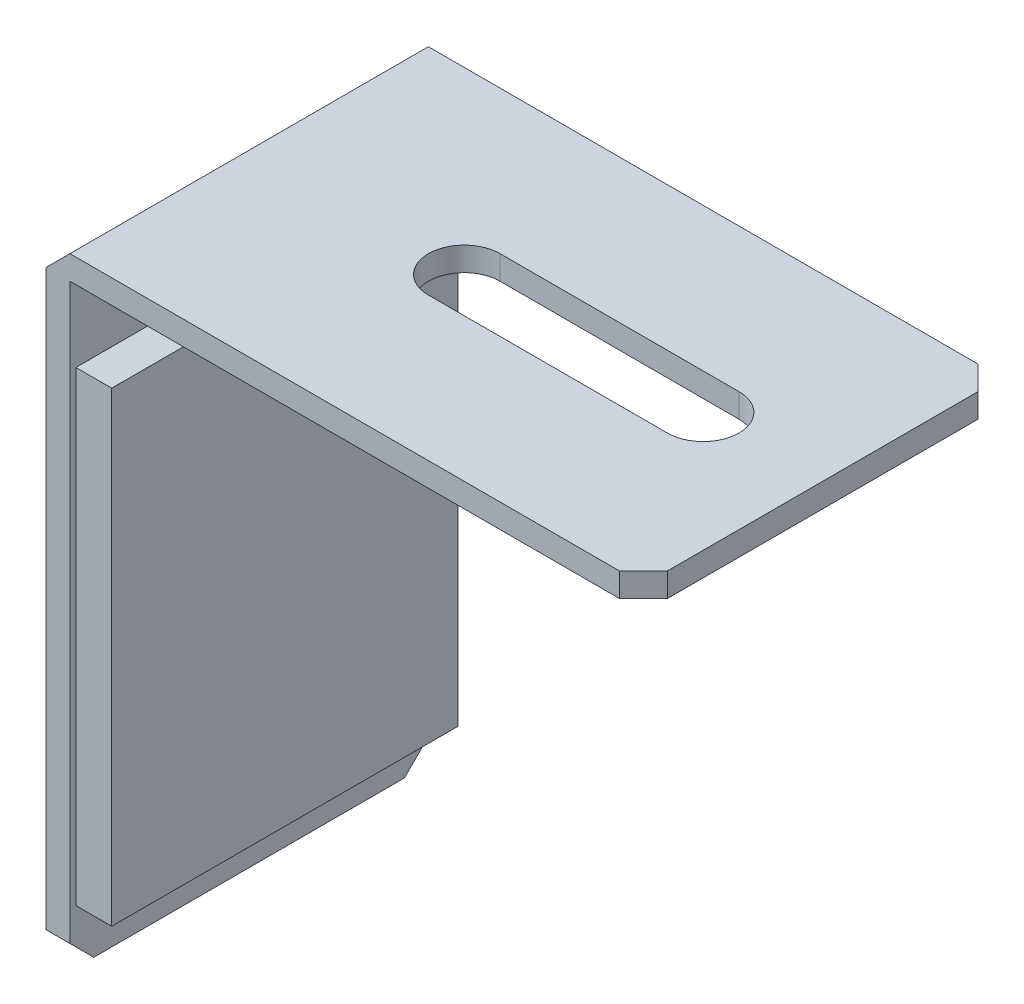
from build123d import *

# Parameters (mm, degrees)
ESBO_O1_W                = 2
ESBO_O1_H                = 50
ESBO_O1_W_2              = 50
ESBO_O1_H_2              = 2
RESSALTO_EXTRUS_O1_DEPTH = 30
CHANFRO1_SIZE            = 2
ESBO_O2_R                = 3
ESBO_O2_W                = 20
ESBO_O2_H                = 6
CORTE_EXTRUS_O1_DEPTH    = 15
ESBO_O3_W                = 29
ESBO_O3_H                = 39
RESSALTO_EXTRUS_O2_DEPTH = 3


with BuildPart() as part:
    # Esboço1 → Ressalto-extrusão1 (new body)
    with BuildSketch(Plane.XY):
        with Locations((1, 25)):
            Rectangle(ESBO_O1_W, ESBO_O1_H)
        with Locations((25, 51)):
            Rectangle(ESBO_O1_W_2, ESBO_O1_H_2)
    extrude(amount=RESSALTO_EXTRUS_O1_DEPTH)

    # Chanfro1
    chanfro1_edges = [part.edges().sort_by_distance(p)[0] for p in [
        (1, 0, 0),
        (50, 51, 0),
        (0, 52, 15),
        (50, 51, 30),
        (1, 0, 30),
    ]]
    chamfer(chanfro1_edges, length=CHANFRO1_SIZE)

    # Esboço2 → Corte-extrusão1 (cut)
    with BuildSketch(Plane(origin=(0, 52, 0), x_dir=(1, 0, 0), z_dir=(0, 1, 0))):
        with Locations((40, -15)):
            Circle(ESBO_O2_R)
        with Locations((20, -15)):
            Circle(ESBO_O2_R)
        with Locations((30, -15)):
            Rectangle(ESBO_O2_W, ESBO_O2_H)
    extrude(amount=-CORTE_EXTRUS_O1_DEPTH, mode=Mode.SUBTRACT)

    # Esboço3 → Ressalto-extrusão2 (add)
    with BuildSketch(Plane(origin=(2, 0, 0), x_dir=(0, 0, -1), z_dir=(1, 0, 0))):
        with Locations((-15, 24)):
            Rectangle(ESBO_O3_W, ESBO_O3_H)
    extrude(amount=RESSALTO_EXTRUS_O2_DEPTH)


solid = part.part
